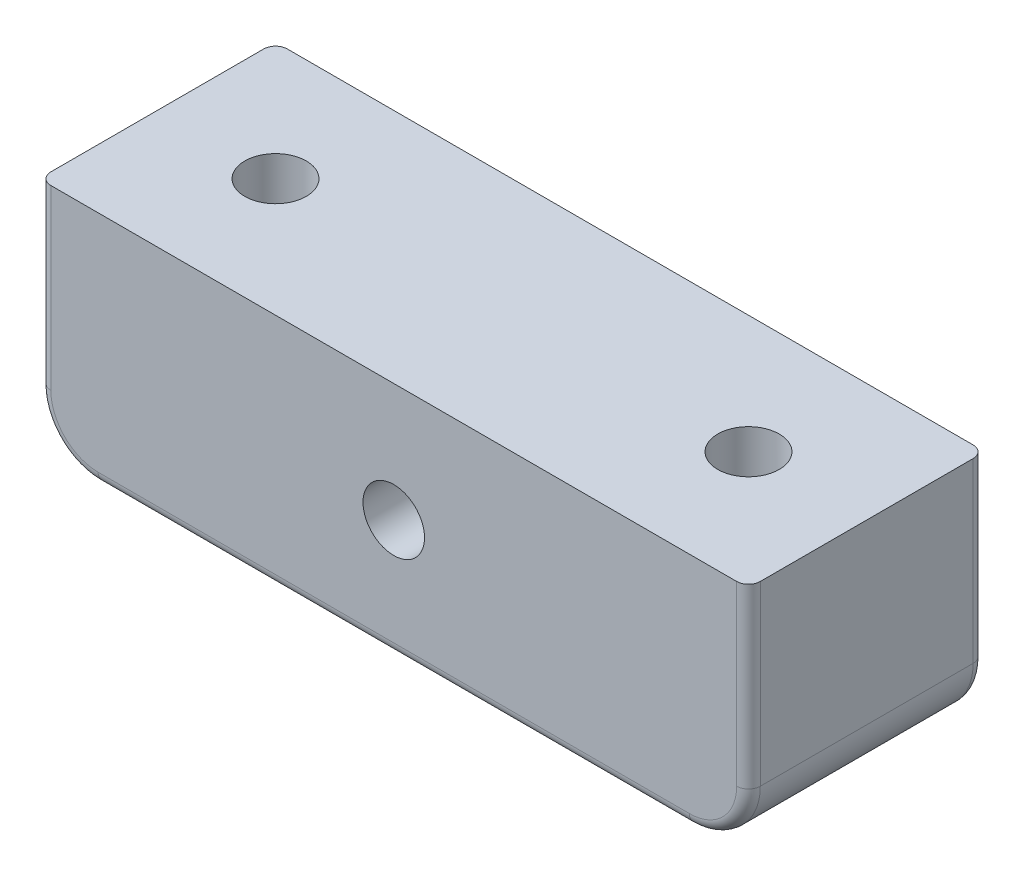
from build123d import *

# Parameters (mm, degrees)
SKETCH1_R           = 2.6
BOSS_EXTRUDE1_DEPTH = 20
SKETCH2_R           = 2.6
CUT_EXTRUDE1_DEPTH  = 20
CUT_EXTRUDE2_DEPTH  = 3
FILLET1_R           = 1


with BuildPart() as part:
    # Sketch1 → Boss-Extrude1 (new body)
    with BuildSketch(Plane.XY):
        with BuildLine():
            Line((-30, 0), (30, 0))
            Line((30, 0), (30, -15))
            ThreePointArc((30, -15), (28.535533906, -18.535533906), (25, -20))
            Line((25, -20), (-25, -20))
            ThreePointArc((-25, -20), (-28.535533906, -18.535533906), (-30, -15))
            Line((-30, -15), (-30, 0))
        make_face()
        with Locations((0, -10)):
            Circle(SKETCH1_R, mode=Mode.SUBTRACT)
    extrude(amount=BOSS_EXTRUDE1_DEPTH)

    # Sketch2 → Cut-Extrude1 (cut)
    with BuildSketch(Plane(origin=(0, 0, 0), x_dir=(1, 0, 0), z_dir=(0, 1, 0))):
        with Locations((-20, -10)):
            Circle(SKETCH2_R)
        with Locations((20, -10)):
            Circle(SKETCH2_R)
    extrude(amount=-CUT_EXTRUDE1_DEPTH, mode=Mode.SUBTRACT)

    # Sketch3 → Cut-Extrude2 (cut)
    with BuildSketch(Plane(origin=(0, 0, 0), x_dir=(-1, 0, 0), z_dir=(0, 0, -1))):
        Polygon((0, -17.505553499), (6.5, -13.75277675), (6.5, -6.24722325), (0, -2.494446501), (-6.5, -6.24722325), (-6.5, -13.75277675), align=None)
    extrude(amount=-CUT_EXTRUDE2_DEPTH, mode=Mode.SUBTRACT)

    # Fillet1
    fillet1_edges = [part.edges().sort_by_distance(p)[0] for p in [
        (0, -20, 20),
        (28.535533906, -18.535533906, 20),
        (30, -7.5, 20),
        (-30, -7.5, 20),
        (30, -7.5, 0),
        (28.535533906, -18.535533906, 0),
        (-28.535533906, -18.535533906, 20),
        (0, -20, 0),
        (-28.535533906, -18.535533906, 0),
        (-30, -7.5, 0),
    ]]
    fillet(fillet1_edges, radius=FILLET1_R)


solid = part.part
